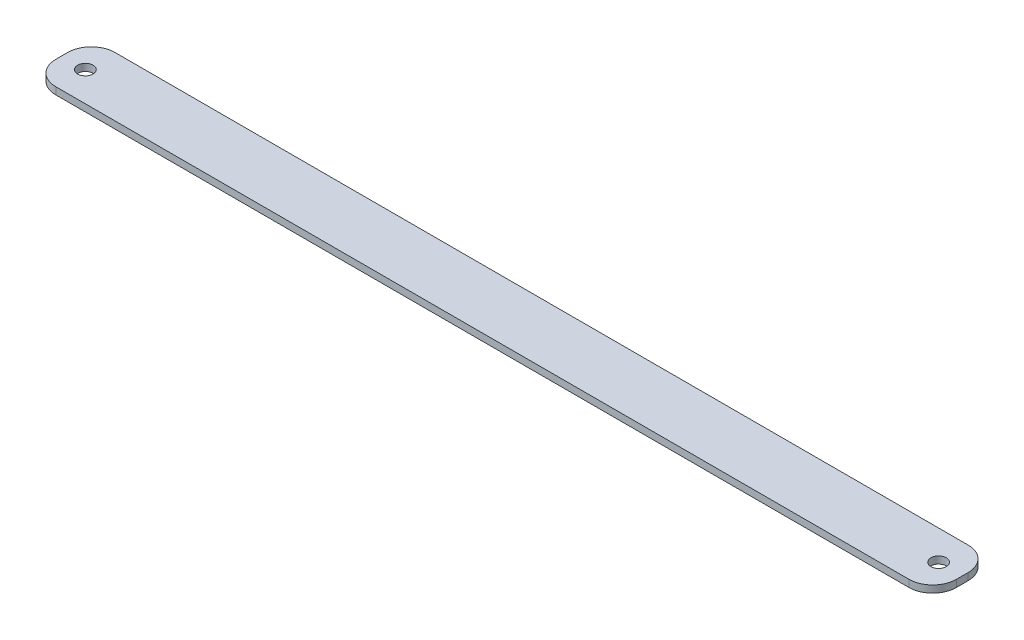
from build123d import *

# Parameters (mm, degrees)
SKETCH1_R           = 3.25
BOSS_EXTRUDE1_DEPTH = 3


with BuildPart() as part:
    # Sketch1 → Boss-Extrude1 (new body)
    with BuildSketch(Plane(origin=(0, 0, 0), x_dir=(1, 0, 0), z_dir=(0, 1, 0))):
        with BuildLine():
            Line((-180, 12.5), (180, 12.5))
            ThreePointArc((180, 12.5), (187.071067812, 9.571067812), (190, 2.5))
            Line((190, 2.5), (190, -2.5))
            ThreePointArc((190, -2.5), (187.071067812, -9.571067812), (180, -12.5))
            Line((180, -12.5), (-180, -12.5))
            ThreePointArc((-180, -12.5), (-187.071067812, -9.571067812), (-190, -2.5))
            Line((-190, -2.5), (-190, 2.5))
            ThreePointArc((-190, 2.5), (-187.071067812, 9.571067812), (-180, 12.5))
        make_face()
        with Locations((-180, 0)):
            Circle(SKETCH1_R, mode=Mode.SUBTRACT)
        with Locations((180, 0)):
            Circle(SKETCH1_R, mode=Mode.SUBTRACT)
    extrude(amount=BOSS_EXTRUDE1_DEPTH)


solid = part.part
